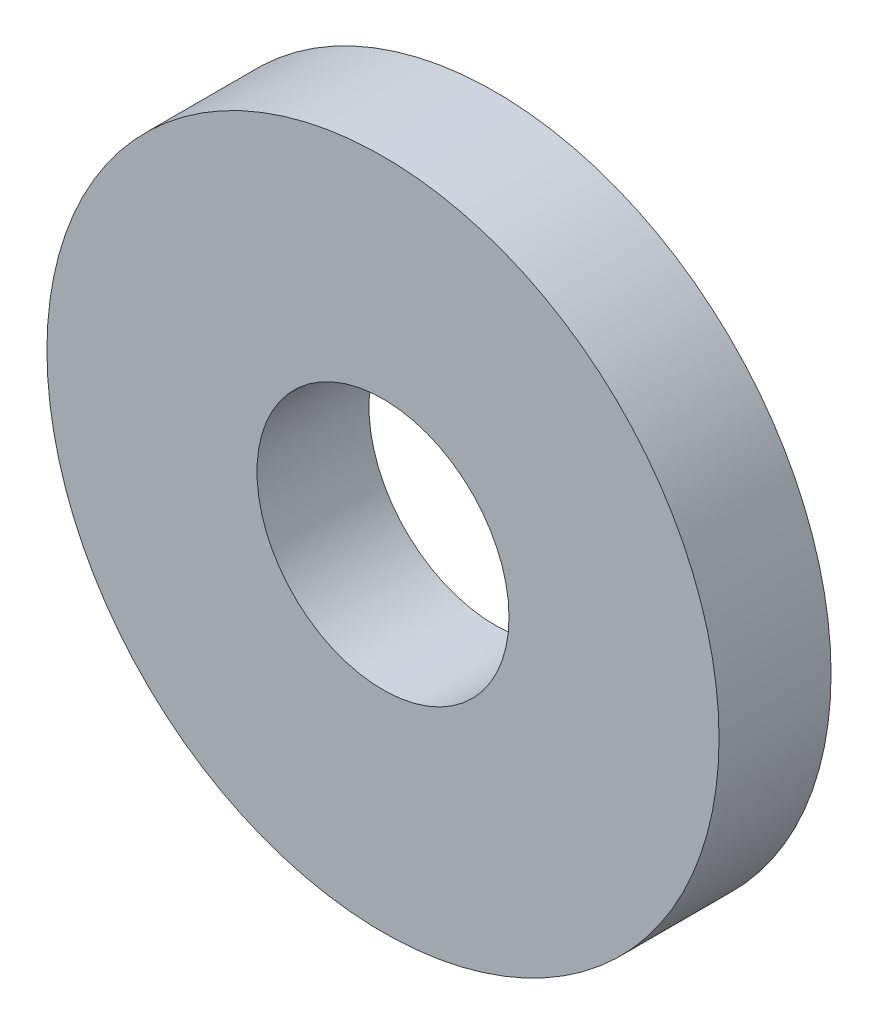
from build123d import *

# Parameters (mm, degrees)
SKETCH1_R           = 6
SKETCH1_R_2         = 2.25
BOSS_EXTRUDE1_DEPTH = 2


with BuildPart() as part:
    # Sketch1 → Boss-Extrude1 (new body)
    with BuildSketch(Plane.XY):
        Circle(SKETCH1_R)
        Circle(SKETCH1_R_2, mode=Mode.SUBTRACT)
    extrude(amount=BOSS_EXTRUDE1_DEPTH)


solid = part.part
